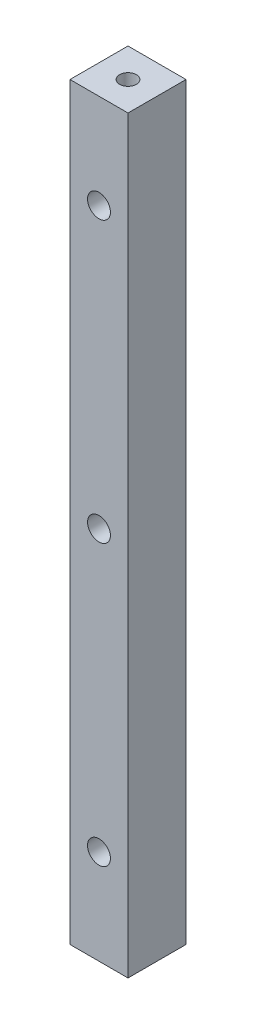
from build123d import *

# Parameters (mm, degrees)
ESQUISSE1_W           = 11.4
ESQUISSE1_H           = 11.4
BOSS_EXTRU_1_DEPTH    = 147.2
TROU_TARAUD_M41_D     = 3.3
TROU_TARAUD_M41_DEPTH = 11.5
TROU_TARAUD_M41_TIP   = 0.991420021
TROU_TARAUD_M42_D     = 3.3
TROU_TARAUD_M42_DEPTH = 11.5
TROU_TARAUD_M42_TIP   = 0.991420021
D_GAGEMENT_M41_D      = 4.5


with BuildPart() as part:
    # Esquisse1 → Boss.-Extru.1 (new body)
    with BuildSketch(Plane(origin=(0, 0, 0), x_dir=(1, 0, 0), z_dir=(0, 1, 0))):
        Rectangle(ESQUISSE1_W, ESQUISSE1_H)
    extrude(amount=BOSS_EXTRU_1_DEPTH)

    # Trou taraudé M41
    with Locations(Plane(origin=(0, 147.2, 0), x_dir=(-1, 0, 0), z_dir=(0, 1, 0))):
        with Locations((0, 0)):
            Hole(TROU_TARAUD_M41_D / 2, depth=TROU_TARAUD_M41_DEPTH)
            with Locations((0, 0, -(TROU_TARAUD_M41_DEPTH + TROU_TARAUD_M41_TIP / 2))):  # 118° drill point
                Cone(0, TROU_TARAUD_M41_D / 2, TROU_TARAUD_M41_TIP, mode=Mode.SUBTRACT)

    # Trou taraudé M42
    with Locations(Plane.XZ):
        with Locations((0, 0)):
            Hole(TROU_TARAUD_M42_D / 2, depth=TROU_TARAUD_M42_DEPTH)
            with Locations((0, 0, -(TROU_TARAUD_M42_DEPTH + TROU_TARAUD_M42_TIP / 2))):  # 118° drill point
                Cone(0, TROU_TARAUD_M42_D / 2, TROU_TARAUD_M42_TIP, mode=Mode.SUBTRACT)

    # Dégagement M41 (through all)
    with Locations(Plane.XY.offset(5.7)):
        with Locations((0, 128.6), (0, 73.6), (0, 18.6)):
            Hole(D_GAGEMENT_M41_D / 2)


solid = part.part
